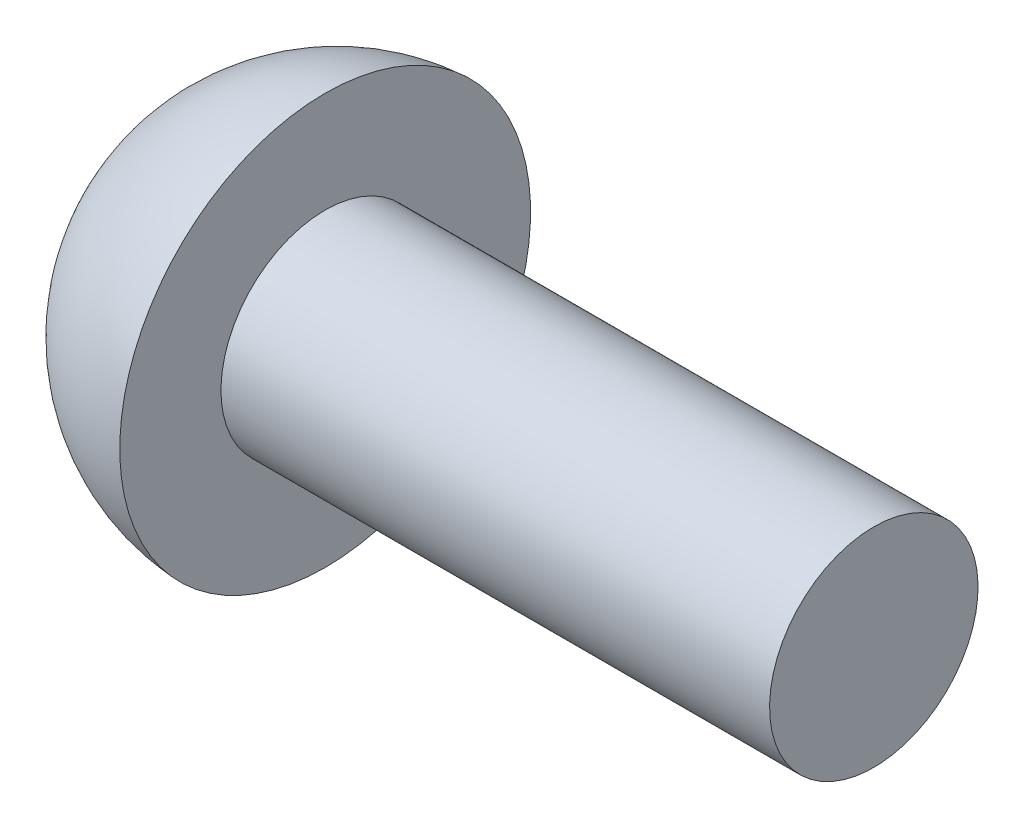
from build123d import *


with BuildPart() as part:
    # Sketch2 → Revolve8 (revolve)
    with BuildSketch(Plane.XY):
        with BuildLine():
            Line((-6.35, 4.754883392), (-6.35, 2.413))
            Line((-6.35, 2.413), (6.35, 2.413))
            Line((6.35, 2.413), (6.35, 0))
            Line((6.35, 0), (-10.84326, 0))
            ThreePointArc((-10.84326, 0), (-9.542238134, 3.27102054), (-6.35, 4.754883392))
        make_face()
    revolve(axis=Axis((6.35, 0, 0), (-1, 0, 0)))


solid = part.part
